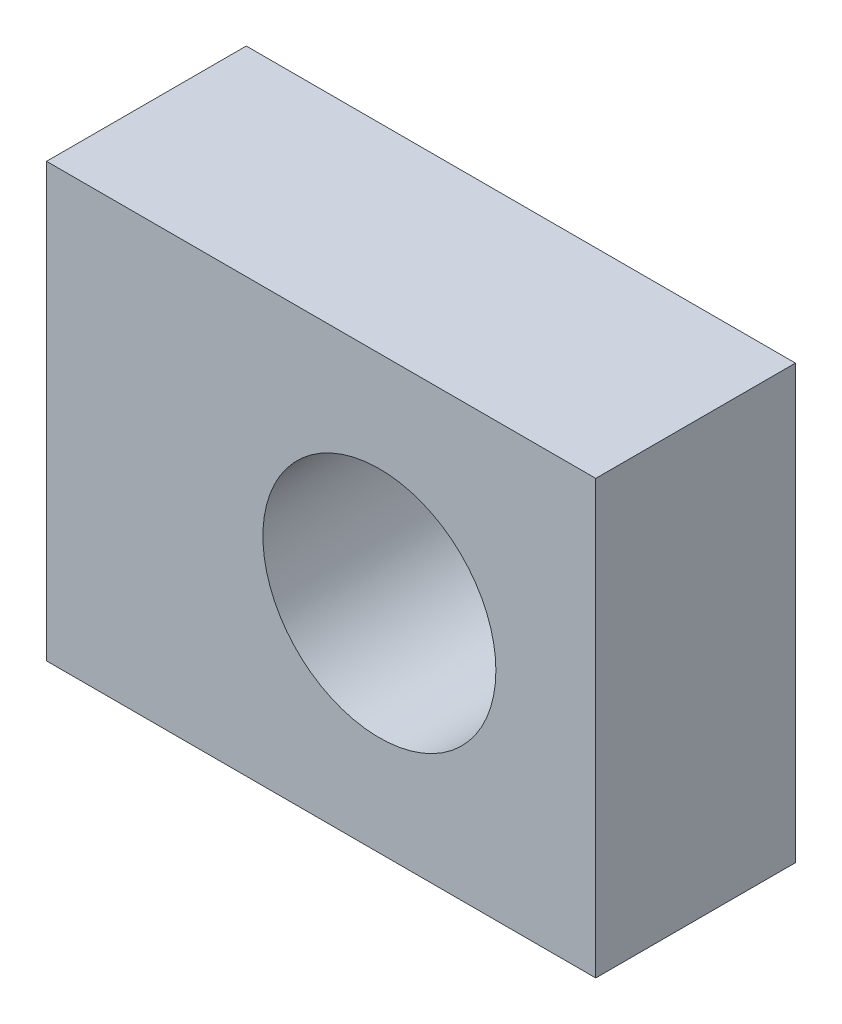
from build123d import *

# Parameters (mm, degrees)
ESQUISSE1_W             = 33
ESQUISSE1_H             = 26
BOSS_EXTRU_1_DEPTH      = 12
ESQUISSE2_R             = 7
ENL_V_MAT_EXTRU_1_DEPTH = 13


with BuildPart() as part:
    # Esquisse1 → Boss.-Extru.1 (new body)
    with BuildSketch(Plane.XY):
        Rectangle(ESQUISSE1_W, ESQUISSE1_H)
    extrude(amount=BOSS_EXTRU_1_DEPTH)

    # Esquisse2 → Enlèv. mat.-Extru.1 (cut, through all)
    with BuildSketch(Plane.XY.offset(12)):
        with Locations((3.5, 0)):
            Circle(ESQUISSE2_R)
    extrude(amount=-ENL_V_MAT_EXTRU_1_DEPTH, mode=Mode.SUBTRACT)


solid = part.part
